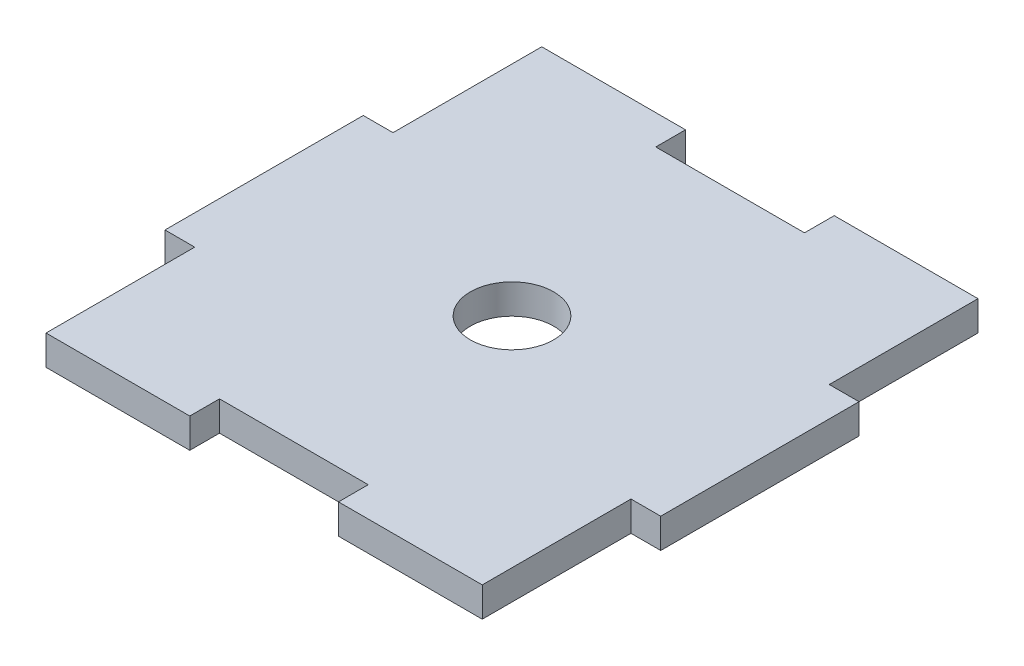
from build123d import *

# Parameters (mm, degrees)
SKETCH_1_R      = 4.2
EXTRUDE_1_DEPTH = 3


with BuildPart() as part:
    # 草图1 → 凸台-拉伸1 (new body)
    with BuildSketch(Plane(origin=(0, 0, 0), x_dir=(1, 0, 0), z_dir=(0, 1, 0))):
        Polygon((22, 25), (22, 10), (25, 10), (25, -10), (22, -10), (22, -25), (7.5, -25), (7.5, -22), (-7.5, -22), (-7.5, -25), (-22, -25), (-22, -10), (-25, -10), (-25, 10), (-22, 10), (-22, 25), (-7.5, 25), (-7.5, 22), (7.5, 22), (7.5, 25), align=None)
        Circle(SKETCH_1_R, mode=Mode.SUBTRACT)
    extrude(amount=EXTRUDE_1_DEPTH)


solid = part.part
